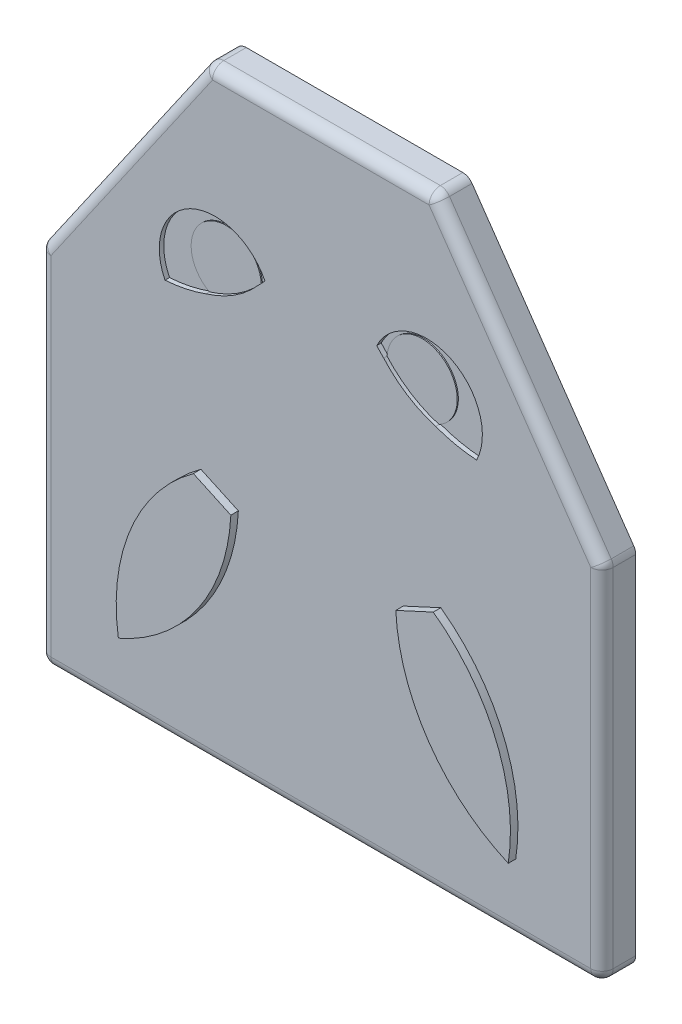
from build123d import *

# Parameters (mm, degrees)
BOSS_EXTRU_1_DEPTH      = 9
BOSS_EXTRU_2_DEPTH      = 2
CONG_1_R                = 3
CONG_2_R                = 3
ENL_V_MAT_EXTRU_2_DEPTH = 1.2
ENL_V_MAT_EXTRU_3_DEPTH = 0.9
BOSS_EXTRU_3_DEPTH      = 2
ESQUISSE9_W             = 60
ESQUISSE9_H             = 2
BOSS_EXTRU_4_DEPTH      = 34
BOSS_EXTRU_5_DEPTH      = 3


with BuildPart() as part:
    # Esquisse1 → Boss.-Extru.1 (new body)
    with BuildSketch(Plane.XY):
        Polygon((-75, 41.958994513), (-30.446686156, 106.182331026), (30.446686156, 106.182331026), (75, 41.958994513), (75, -54.666809259), (-75, -54.666809259), align=None)
        Polygon((73, -52.666809259), (-73, -52.666809259), (-73, 41.333190741), (-29.4, 104.182331026), (29.4, 104.182331026), (73, 41.333190741), align=None, mode=Mode.SUBTRACT)
    extrude(amount=-BOSS_EXTRU_1_DEPTH)

    # Esquisse2 → Boss.-Extru.2 (add)
    with BuildSketch(Plane.XY):
        Polygon((-73, 41.333190741), (-29.4, 104.182331026), (29.4, 104.182331026), (73, 41.333190741), (73, -52.666809259), (-73, -52.666809259), align=None)
    extrude(amount=-BOSS_EXTRU_2_DEPTH)

    # Congé1
    cong_1_edges = [part.edges().sort_by_distance(p)[0] for p in [
        (29.4, 104.182331026, -5.5),
        (73, 41.333190741, -5.5),
        (73, -52.666809259, -5.5),
        (-73, -52.666809259, -5.5),
        (-73, 41.333190741, -5.5),
        (-29.4, 104.182331026, -5.5),
    ]]
    fillet(cong_1_edges, radius=CONG_1_R)

    # Congé2
    cong_2_edges = [part.edges().sort_by_distance(p)[0] for p in [
        (-75, 41.958994513, -4.5),
        (-30.446686156, 106.182331026, -4.5),
        (30.446686156, 106.182331026, -4.5),
        (75, 41.958994513, -4.5),
        (75, -54.666809259, -4.5),
        (-75, -54.666809259, -4.5),
        (-52.723343078, 74.07066277, 0),
        (0, 106.182331026, 0),
        (52.723343078, 74.07066277, 0),
        (75, -6.353907373, 0),
        (0, -54.666809259, 0),
        (-75, -6.353907373, 0),
    ]]
    fillet(cong_2_edges, radius=CONG_2_R)

    # Esquisse3 → Enlèv. mat.-Extru.2 (cut)
    with BuildSketch(Plane.XY):
        with BuildLine():
            ThreePointArc((14.913911185, 63.744265219), (15.827091675, 62.73511926), (16.775234523, 61.75874878))
            ThreePointArc((16.775234523, 61.75874878), (31.162887196, 69.020353616), (30.632630303, 52.91276901))
            ThreePointArc((30.632630303, 52.91276901), (36.012189208, 51.35807643), (41.559939675, 50.597032557))
            ThreePointArc((41.559939675, 50.597032557), (34.810541761, 70.493663133), (14.913911185, 63.744265219))
        make_face()
        with BuildLine():
            ThreePointArc((-16.775234523, 61.75874878), (-15.827091675, 62.73511926), (-14.913911185, 63.744265219))
            ThreePointArc((-14.913911185, 63.744265219), (-34.810541761, 70.493663133), (-41.559939675, 50.597032557))
            ThreePointArc((-41.559939675, 50.597032557), (-36.012189208, 51.35807643), (-30.632630303, 52.91276901))
            ThreePointArc((-30.632630303, 52.91276901), (-31.162887196, 69.020353616), (-16.775234523, 61.75874878))
        make_face()
    extrude(amount=-ENL_V_MAT_EXTRU_2_DEPTH, mode=Mode.SUBTRACT)

    # Esquisse7 → Enlèv. mat.-Extru.3 (cut)
    with BuildSketch(Plane.XY):
        with BuildLine():
            ThreePointArc((-30.632630303, 52.91276901), (-31.162887196, 69.020353616), (-16.775234523, 61.75874878))
            ThreePointArc((-16.775234523, 61.75874878), (-23.08615551, 56.36799961), (-30.632630303, 52.91276901))
        make_face()
        with BuildLine():
            ThreePointArc((30.632630303, 52.91276901), (31.16562065, 69.024635625), (16.775234523, 61.75874878))
            ThreePointArc((16.775234523, 61.75874878), (23.08615551, 56.36799961), (30.632630303, 52.91276901))
        make_face()
    extrude(amount=-ENL_V_MAT_EXTRU_3_DEPTH, mode=Mode.SUBTRACT)

    # Esquisse8 → Boss.-Extru.3 (add)
    with BuildSketch(Plane.XY):
        with BuildLine():
            Line((-22, 7.097367508), (-32, 11.705065554))
            ThreePointArc((-32, 11.705065554), (-48.741759908, -9.507732006), (-52, -36.334084286))
            ThreePointArc((-52, -36.334084286), (-30.801710364, -18.899787662), (-22, 7.097367508))
        make_face()
        with BuildLine():
            Line((22, 7.097367508), (32, 11.705065554))
            ThreePointArc((32, 11.705065554), (48.741759908, -9.507732006), (52, -36.334084286))
            ThreePointArc((52, -36.334084286), (30.801710364, -18.899787662), (22, 7.097367508))
        make_face()
    extrude(amount=BOSS_EXTRU_3_DEPTH)

    # Esquisse9 → Boss.-Extru.4 (add)
    with BuildSketch(Plane(origin=(0, 0, -9), x_dir=(-1, 0, 0), z_dir=(0, 0, -1))):
        with Locations((0, -53.666809259)):
            Rectangle(ESQUISSE9_W, ESQUISSE9_H)
    extrude(amount=BOSS_EXTRU_4_DEPTH)

    # Esquisse10 → Boss.-Extru.5 (add)
    with BuildSketch(Plane(origin=(0, -52.666809259, 0), x_dir=(1, 0, 0), z_dir=(0, 1, 0))):
        with BuildLine():
            Line((25, 41), (-25, 41))
            ThreePointArc((-25, 41), (0, 16), (25, 41))
        make_face()
    extrude(amount=BOSS_EXTRU_5_DEPTH)


solid = part.part
